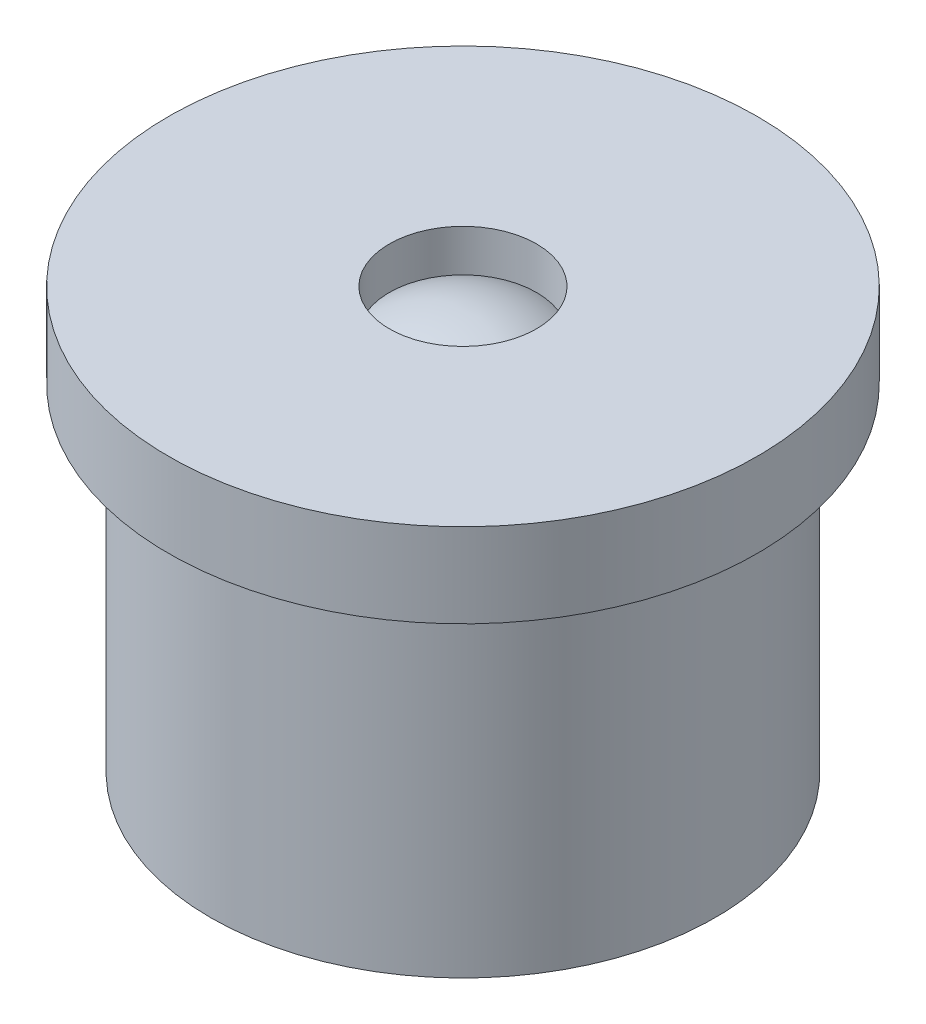
from build123d import *


with BuildPart() as part:
    # Sketch1 → Revolve1 (revolve)
    with BuildSketch(Plane(origin=(0, 0, 0), x_dir=(0, 0, -1), z_dir=(1, 0, 0))):
        with BuildLine():
            Line((1.75, 9), (1.75, 10))
            Line((1.75, 10), (7, 10))
            Line((7, 10), (7, 8))
            Line((7, 8), (6, 8))
            Line((6, 8), (6, 0))
            Line((6, 0), (0, 0))
            Line((0, 0), (0, 9.5))
            ThreePointArc((0, 9.5), (0.910013736, 9.372548077), (1.75, 9))
        make_face()
    revolve(axis=Axis((0, 0, 0), (0, 1, 0)))


solid = part.part
